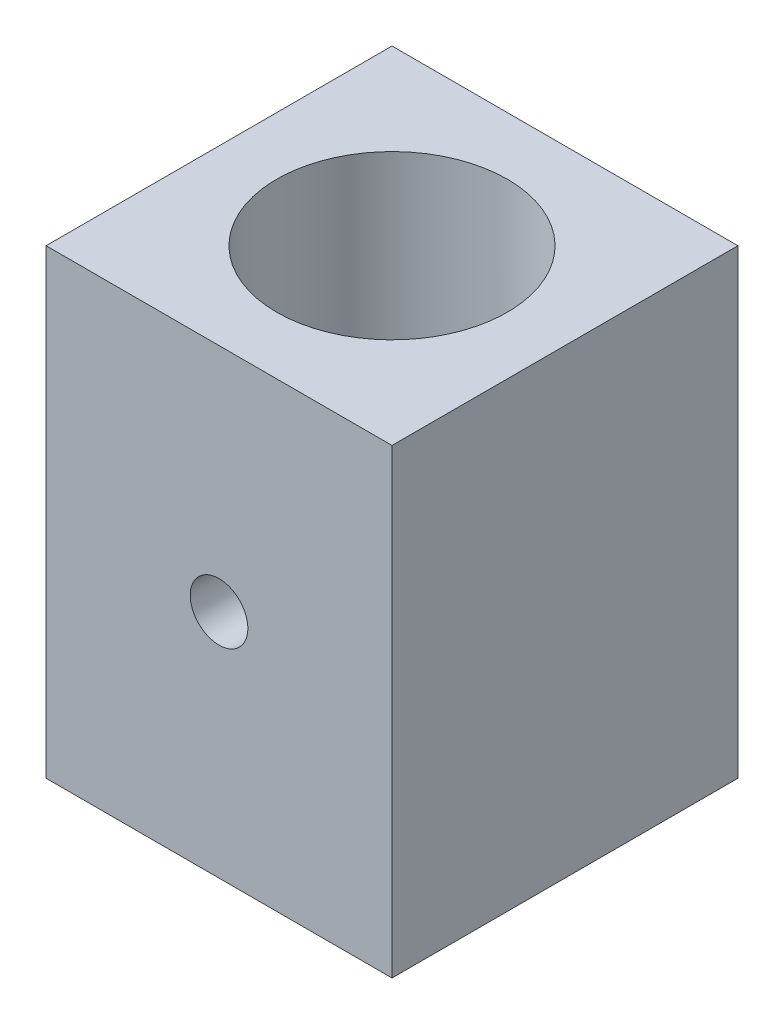
from build123d import *

# Parameters (mm, degrees)
SKETCH3_W           = 76.2
SKETCH3_H           = 76.2
BOSS_EXTRUDE2_DEPTH = 101.6
SKETCH4_R           = 6.35
CUT_EXTRUDE2_DEPTH  = 73.914
SKETCH5_R           = 25.4
CUT_EXTRUDE3_DEPTH  = 113.538
SKETCH7_R           = 6.35
CUT_EXTRUDE4_DEPTH  = 18.034


with BuildPart() as part:
    # Sketch3 → Boss-Extrude2 (new body)
    with BuildSketch(Plane(origin=(0, 0, 0), x_dir=(1, 0, 0), z_dir=(0, 1, 0))):
        with Locations((38.1, 38.1)):
            Rectangle(SKETCH3_W, SKETCH3_H)
    extrude(amount=BOSS_EXTRUDE2_DEPTH)

    # Sketch4 → Cut-Extrude2 (cut)
    with BuildSketch(Plane.XY):
        with Locations((38.1, 50.8)):
            Circle(SKETCH4_R)
    extrude(amount=-CUT_EXTRUDE2_DEPTH, mode=Mode.SUBTRACT)

    # Sketch5 → Cut-Extrude3 (cut)
    with BuildSketch(Plane(origin=(0, 101.6, 0), x_dir=(1, 0, 0), z_dir=(0, 1, 0))):
        with Locations(Location((38.1, 38.1, 0), (0, 0, 270))):
            Circle(SKETCH5_R)
    extrude(amount=-CUT_EXTRUDE3_DEPTH, mode=Mode.SUBTRACT)

    # Sketch7 → Cut-Extrude4 (cut)
    with BuildSketch(Plane(origin=(0, 0, -76.2), x_dir=(-1, 0, 0), z_dir=(0, 0, -1))):
        with Locations(Location((-38.1, 50.8, 0), (0, 0, 180))):
            Circle(SKETCH7_R)
    extrude(amount=-CUT_EXTRUDE4_DEPTH, mode=Mode.SUBTRACT)


solid = part.part
